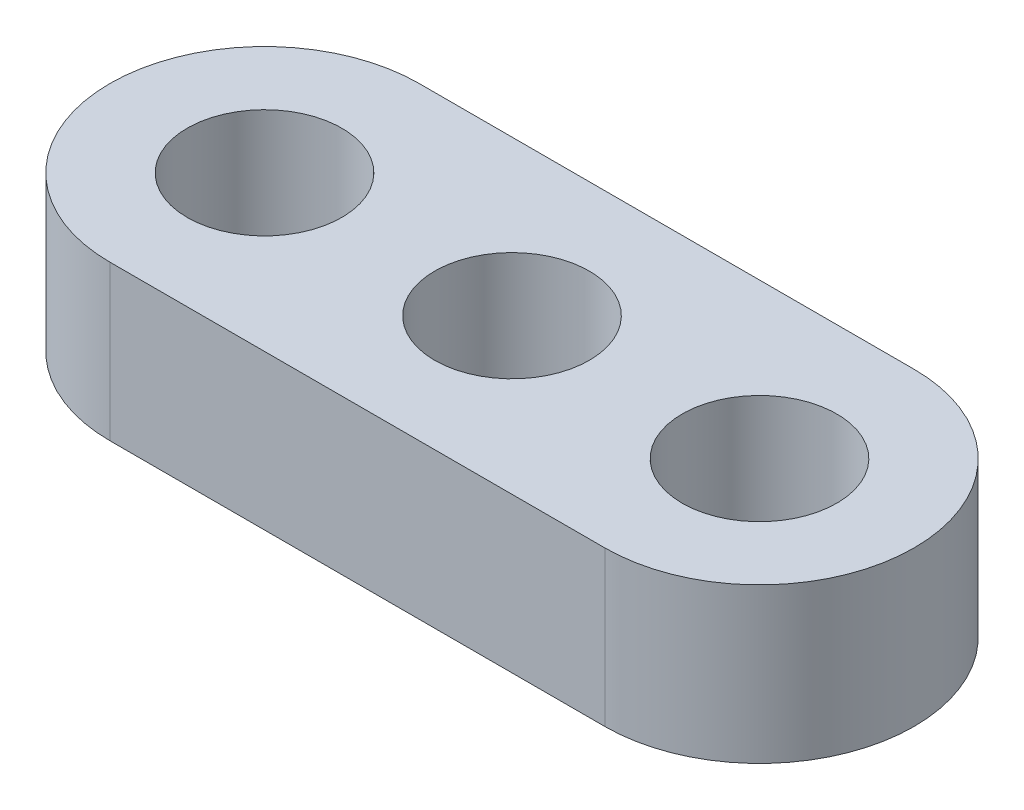
from build123d import *

# Parameters (mm, degrees)
SKETCH1_R           = 1.5875
BOSS_EXTRUDE1_DEPTH = 3.175


with BuildPart() as part:
    # Sketch1 → Boss-Extrude1 (new body)
    with BuildSketch(Plane(origin=(0, 0, 0), x_dir=(1, 0, 0), z_dir=(0, 1, 0))):
        with BuildLine():
            Line((10.16, 3.175), (0, 3.175))
            ThreePointArc((0, 3.175), (-3.175, 0), (0, -3.175))
            Line((0, -3.175), (10.16, -3.175))
            ThreePointArc((10.16, -3.175), (13.335, 0), (10.16, 3.175))
        make_face()
        with Locations(Location((0, 0, 0), (0, 0, 270))):
            Circle(SKETCH1_R, mode=Mode.SUBTRACT)
        with Locations(Location((5.08, 0, 0), (0, 0, 270))):
            Circle(SKETCH1_R, mode=Mode.SUBTRACT)
        with Locations(Location((10.16, 0, 0), (0, 0, 270))):
            Circle(SKETCH1_R, mode=Mode.SUBTRACT)
    extrude(amount=BOSS_EXTRUDE1_DEPTH)


solid = part.part
